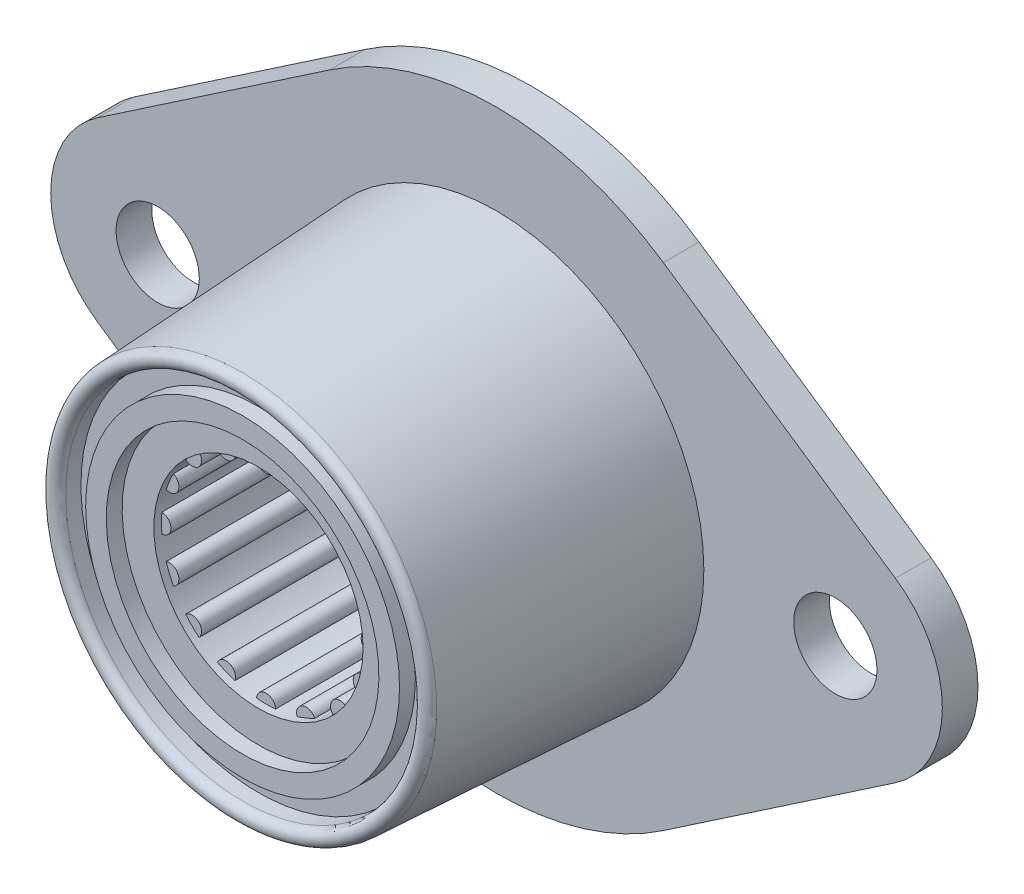
from build123d import *

# Parameters (mm, degrees)
SKETCH1_R          = 2.778125
SKETCH1_R_2        = 13.843
EXTRUDE1_DEPTH     = 2.38125
CUT_EXTRUDE2_DEPTH = 19.276940811
SKETCH4_R          = 6.985
CUT_EXTRUDE3_DEPTH = 0.508
SKETCH5_R          = 6.985
CUT_EXTRUDE4_DEPTH = 0.508


with BuildPart() as part:
    # Sketch1 → Extrude1 (new body)
    with BuildSketch(Plane.XY):
        with BuildLine():
            Line((-26.632401316, 5.911754624), (-11.140350877, 16.421540622))
            ThreePointArc((-11.140350877, 16.421540622), (0, 19.84375), (11.140350877, 16.421540622))
            Line((11.140350877, 16.421540622), (26.632401316, 5.911754624))
            ThreePointArc((26.632401316, 5.911754624), (29.765625, 0), (26.632401316, -5.911754624))
            Line((26.632401316, -5.911754624), (11.140350877, -16.421540622))
            ThreePointArc((11.140350877, -16.421540622), (0, -19.84375), (-11.140350877, -16.421540622))
            Line((-11.140350877, -16.421540622), (-26.632401316, -5.911754624))
            ThreePointArc((-26.632401316, -5.911754624), (-29.765625, 0), (-26.632401316, 5.911754624))
        make_face()
        with Locations((-22.621875, 0)):
            Circle(SKETCH1_R, mode=Mode.SUBTRACT)
        with Locations((22.621875, 0)):
            Circle(SKETCH1_R, mode=Mode.SUBTRACT)
        Circle(SKETCH1_R_2, mode=Mode.SUBTRACT)
    extrude(amount=EXTRUDE1_DEPTH)

    # Sketch2 → Revolve1 (revolve)
    with BuildSketch(Plane(origin=(0, 0, 0), x_dir=(0, 0, -1), z_dir=(1, 0, 0))):
        with BuildLine():
            Line((0, 13.843), (-2.38125, 13.843))
            Line((-2.38125, 13.843), (-19.321767937, 12.955185075))
            ThreePointArc((-19.321767937, 12.955185075), (-19.69248368, 12.784282777), (-19.84375, 12.405130751))
            ThreePointArc((-19.84375, 12.405130751), (-19.682421724, 12.015649839), (-19.292940811, 11.854321563))
            Line((-19.292940811, 11.854321563), (-18.276940811, 11.854321563))
            Line((-18.276940811, 11.854321563), (-18.276940811, 10.478241172))
            Line((-18.276940811, 10.478241172), (-19.33575, 10.478241172))
            Line((-19.33575, 10.478241172), (-19.33575, 9.102160781))
            Line((-19.33575, 9.102160781), (-18.276940811, 9.102160781))
            Line((-18.276940811, 9.102160781), (-18.276940811, 7.726080391))
            Line((-18.276940811, 7.726080391), (-18.276940811, 6.35))
            Line((-18.276940811, 6.35), (0, 6.35))
            Line((0, 6.35), (0, 13.843))
        make_face()
    revolve(axis=Axis((0, 0, 0), (0, 0, 1)))

    # Sketch3 → Cut-Extrude2 (cut, through all)
    with BuildSketch(Plane.XY.offset(18.276940811)):
        with BuildLine():
            ThreePointArc((-3.248055272, 6.183879199), (-3.880658078, 5.807815242), (-4.470182484, 5.367279904))
            ThreePointArc((-4.470182484, 5.367279904), (-4.490128061, 4.490128061), (-5.367279904, 4.470182484))
            ThreePointArc((-5.367279904, 4.470182484), (-5.807815242, 3.880658078), (-6.183879199, 3.248055272))
            ThreePointArc((-6.183879199, 3.248055272), (-5.866635031, 2.430039796), (-6.669384824, 2.075941007))
            ThreePointArc((-6.669384824, 2.075941007), (-6.850785184, 1.362705899), (-6.956136364, 0.634343669))
            ThreePointArc((-6.956136364, 0.634343669), (-6.35, 0), (-6.956136364, -0.634343669))
            ThreePointArc((-6.956136364, -0.634343669), (-6.850785184, -1.362705899), (-6.669384824, -2.075941007))
            ThreePointArc((-6.669384824, -2.075941007), (-5.866635031, -2.430039796), (-6.183879199, -3.248055272))
            ThreePointArc((-6.183879199, -3.248055272), (-5.807815242, -3.880658078), (-5.367279904, -4.470182484))
            ThreePointArc((-5.367279904, -4.470182484), (-4.490128061, -4.490128061), (-4.470182484, -5.367279904))
            ThreePointArc((-4.470182484, -5.367279904), (-3.880658078, -5.807815242), (-3.248055272, -6.183879199))
            ThreePointArc((-3.248055272, -6.183879199), (-2.430039796, -5.866635031), (-2.075941007, -6.669384824))
            ThreePointArc((-2.075941007, -6.669384824), (-1.362705899, -6.850785184), (-0.634343669, -6.956136364))
            ThreePointArc((-0.634343669, -6.956136364), (0, -6.35), (0.634343669, -6.956136364))
            ThreePointArc((0.634343669, -6.956136364), (1.362705899, -6.850785184), (2.075941007, -6.669384824))
            ThreePointArc((2.075941007, -6.669384824), (2.430039796, -5.866635031), (3.248055272, -6.183879199))
            ThreePointArc((3.248055272, -6.183879199), (3.880658078, -5.807815242), (4.470182484, -5.367279904))
            ThreePointArc((4.470182484, -5.367279904), (4.490128061, -4.490128061), (5.367279904, -4.470182484))
            ThreePointArc((5.367279904, -4.470182484), (5.807815242, -3.880658078), (6.183879199, -3.248055272))
            ThreePointArc((6.183879199, -3.248055272), (5.866635031, -2.430039796), (6.669384824, -2.075941007))
            ThreePointArc((6.669384824, -2.075941007), (6.850785184, -1.362705899), (6.956136364, -0.634343669))
            ThreePointArc((6.956136364, -0.634343669), (6.35, 0), (6.956136364, 0.634343669))
            ThreePointArc((6.956136364, 0.634343669), (6.850785184, 1.362705899), (6.669384824, 2.075941007))
            ThreePointArc((6.669384824, 2.075941007), (5.866635031, 2.430039796), (6.183879199, 3.248055272))
            ThreePointArc((6.183879199, 3.248055272), (5.807815242, 3.880658078), (5.367279904, 4.470182484))
            ThreePointArc((5.367279904, 4.470182484), (4.490128061, 4.490128061), (4.470182484, 5.367279904))
            ThreePointArc((4.470182484, 5.367279904), (3.880658078, 5.807815242), (3.248055272, 6.183879199))
            ThreePointArc((3.248055272, 6.183879199), (2.430039796, 5.866635031), (2.075941007, 6.669384824))
            ThreePointArc((2.075941007, 6.669384824), (1.362705899, 6.850785184), (0.634343669, 6.956136364))
            ThreePointArc((0.634343669, 6.956136364), (0, 6.35), (-0.634343669, 6.956136364))
            ThreePointArc((-0.634343669, 6.956136364), (-1.362705899, 6.850785184), (-2.075941007, 6.669384824))
            ThreePointArc((-2.075941007, 6.669384824), (-2.430039796, 5.866635031), (-3.248055272, 6.183879199))
        make_face()
    extrude(amount=-CUT_EXTRUDE2_DEPTH, mode=Mode.SUBTRACT)

    # Sketch4 → Cut-Extrude3 (cut)
    with BuildSketch(Plane.XY.offset(18.276940811)):
        Circle(SKETCH4_R)
    extrude(amount=-CUT_EXTRUDE3_DEPTH, mode=Mode.SUBTRACT)

    # Sketch5 → Cut-Extrude4 (cut)
    with BuildSketch(Plane(origin=(0, 0, 0), x_dir=(-1, 0, 0), z_dir=(0, 0, -1))):
        Circle(SKETCH5_R)
    extrude(amount=-CUT_EXTRUDE4_DEPTH, mode=Mode.SUBTRACT)


solid = part.part
